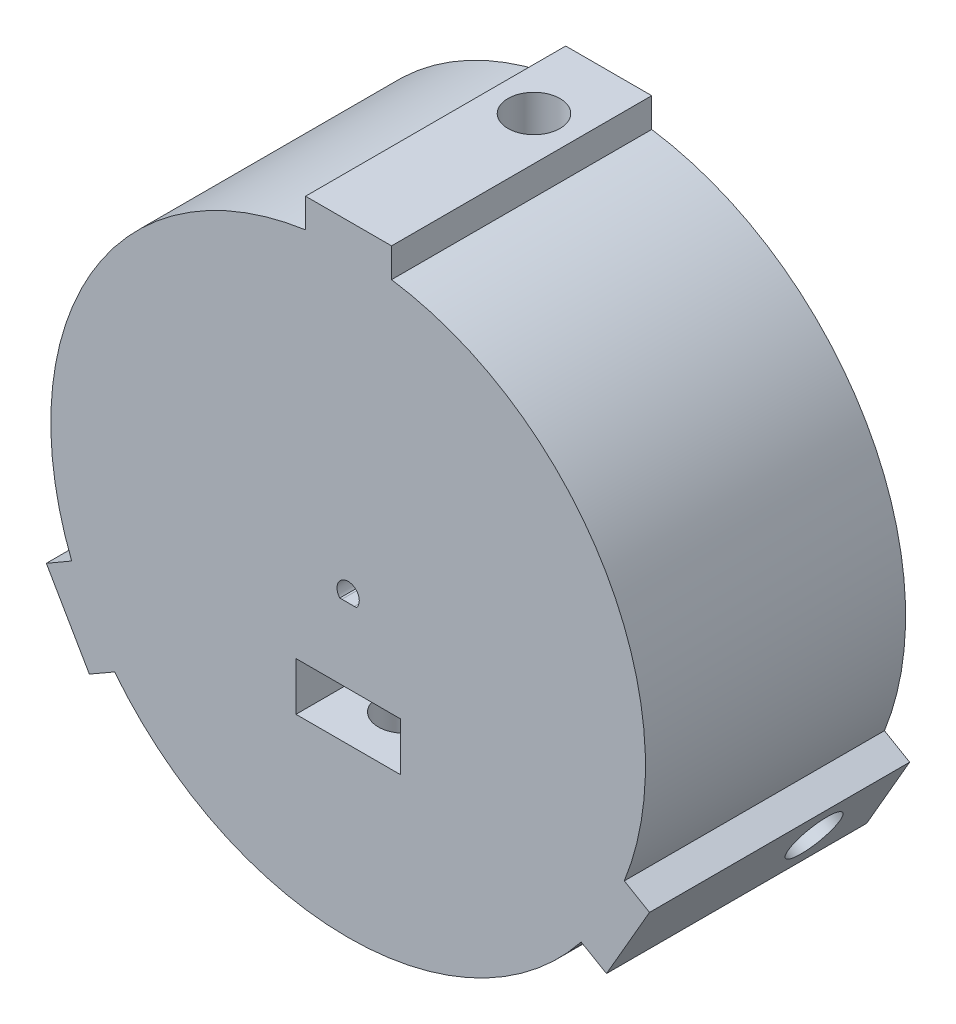
from build123d import *

# Parameters (mm, degrees)
SKETCH2_R                = 40
BOSS_EXTRUDE1_DEPTH      = 35
SKETCH3_W                = 8
SKETCH3_H                = 35
CUT_EXTRUDE1_DEPTH       = 20
SKETCH4_R                = 3.5
CUT_EXTRUDE2_DEPTH       = 80
SKETCH5_R                = 3.5
CUT_EXTRUDE3_DEPTH       = 50
SKETCH6_R                = 3.5
CUT_EXTRUDE4_DEPTH       = 50
SKETCH8_W                = 14.038446545
SKETCH8_H                = 6.5
CUT_EXTRUDE5_DEPTH       = 15.5
SKETCH11_W               = 8
SKETCH11_H               = 6.5
BOSS_EXTRUDE2_DEPTH      = 4.5
BOSS_EXTRUDE3_DEPTH      = 15.5
BOSS_EXTRUDE4_DEPTH      = 35
SKETCH18_R               = 3.5
CUT_EXTRUDE9_DEPTH       = 25
SKETCH19_R               = 3.5
CUT_EXTRUDE10_DEPTH      = 25
SKETCH20_R               = 3.5
CUT_EXTRUDE11_DEPTH      = 25
SKETCH21_W               = 5.1
SKETCH21_H               = 18.4
CUT_EXTRUDE12_DEPTH      = 13
SKETCH23_W               = 5.1
SKETCH23_H               = 18.4
CUT_EXTRUDE13_DEPTH      = 13
SKETCH22_W               = 5.1
SKETCH22_H               = 13.3
BOSS_EXTRUDE5_DEPTH      = 7.9
CUT_EXTRUDE14_DEPTH      = 8.5
SKETCH25_R               = 9
CUT_EXTRUDE15_DEPTH      = 20
SKETCH27_W               = 14.038446545
SKETCH27_H               = 6.5
CUT_EXTRUDE16_DEPTH      = 13
SKETCH28_R               = 3.5
CUT_EXTRUDE18_DEPTH      = 18
CUT_EXTRUDE18_DEPTH_BACK = 50


with BuildPart() as part:
    # Sketch2 → Boss-Extrude1 (new body)
    with BuildSketch(Plane.XY):
        Circle(SKETCH2_R)
    extrude(amount=BOSS_EXTRUDE1_DEPTH)

    # Sketch3 → Cut-Extrude1 (cut)
    with BuildSketch(Plane(origin=(0, 0, 0), x_dir=(-1, 0, 0), z_dir=(0, 0, -1))):
        with Locations((0, 21.5)):
            Rectangle(SKETCH3_W, SKETCH3_H)
        Polygon((31.774990748, -22.964101615), (35.774990748, -16.035898385), (5.464101615, 1.464101615), (1.464101615, -5.464101615), align=None)
        Polygon((-35.774990748, -16.035898385), (-31.774990748, -22.964101615), (-1.464101615, -5.464101615), (-5.464101615, 1.464101615), align=None)
    extrude(amount=-CUT_EXTRUDE1_DEPTH, mode=Mode.SUBTRACT)

    # Sketch4 → Cut-Extrude2 (cut)
    with BuildSketch(Plane(origin=(-3.464101615, -2, 0), x_dir=(0, 0, 1), z_dir=(-0.866025404, -0.5, 0))):
        with Locations((10, 0)):
            Circle(SKETCH4_R)
    extrude(amount=CUT_EXTRUDE2_DEPTH, mode=Mode.SUBTRACT)

    # Sketch5 → Cut-Extrude3 (cut)
    with BuildSketch(Plane(origin=(0, 4, 0), x_dir=(1, 0, 0), z_dir=(0, 1, 0))):
        with Locations((0, -10)):
            Circle(SKETCH5_R)
    extrude(amount=CUT_EXTRUDE3_DEPTH, mode=Mode.SUBTRACT)

    # Sketch6 → Cut-Extrude4 (cut)
    with BuildSketch(Plane(origin=(3.464101615, -2, 0), x_dir=(0, 0, -1), z_dir=(0.866025404, -0.5, 0))):
        with Locations((-10, 0)):
            Circle(SKETCH6_R)
    extrude(amount=CUT_EXTRUDE4_DEPTH, mode=Mode.SUBTRACT)

    # Sketch8 → Cut-Extrude5 (cut)
    with BuildSketch(Plane(origin=(0, 0, 0), x_dir=(-1, 0, 0), z_dir=(0, 0, -1))):
        Polygon((-32.971083956, -10.892407408), (-25.951860683, -23.050058746), (-20.322695558, -19.800058746), (-27.341918831, -7.642407408), align=None)
        with Locations((0.033217181, 30.75)):
            Rectangle(SKETCH8_W, SKETCH8_H)
        Polygon((27.30870165, -7.699941254), (32.937866774, -10.949941254), (25.918643502, -23.107592592), (20.289478377, -19.857592592), align=None)
    extrude(amount=-CUT_EXTRUDE5_DEPTH, mode=Mode.SUBTRACT)

    # Sketch11 → Boss-Extrude2 (add)
    with BuildSketch(Plane(origin=(0, 0, 20), x_dir=(-1, 0, 0), z_dir=(0, 0, -1))):
        with Locations((0, 30.75)):
            Rectangle(SKETCH11_W, SKETCH11_H)
        Polygon((25.815698604, -10.285898385), (31.444863729, -13.535898385), (27.444863729, -20.464101615), (21.815698604, -17.214101615), align=None)
        Polygon((-21.815698604, -17.214101615), (-27.444863729, -20.464101615), (-31.444863729, -13.535898385), (-25.815698604, -10.285898385), align=None)
    extrude(amount=BOSS_EXTRUDE2_DEPTH)

    # Sketch12 → Boss-Extrude3 (add)
    with BuildSketch(Plane(origin=(0, 0, 15.5), x_dir=(-1, 0, 0), z_dir=(0, 0, -1))):
        Polygon((-6.986006091, 32.1), (7.052440454, 32.1), (7.052440454, 34), (4, 34), (4, 39), (-4, 39), (-4, 34), (-6.986006091, 34), align=None)
        Polygon((25.918643502, -23.107592592), (27.444863729, -20.464101615), (31.774990748, -22.964101615), (35.774990748, -16.035898385), (31.444863729, -13.535898385), (32.937866774, -10.949941254), (31.292418507, -9.999941254), (24.273195235, -22.157592592), align=None)
        Polygon((-32.971083956, -10.892407408), (-31.444863729, -13.535898385), (-35.774990748, -16.035898385), (-31.774990748, -22.964101615), (-27.444863729, -20.464101615), (-25.951860683, -23.050058746), (-24.306412416, -22.100058746), (-31.325635688, -9.942407408), align=None)
    extrude(amount=BOSS_EXTRUDE3_DEPTH)

    # Sketch17 → Boss-Extrude4 (add)
    with BuildSketch(Plane(origin=(0, 0, 0), x_dir=(-1, 0, 0), z_dir=(0, 0, -1))):
        Polygon((-5.842787082, 32.897450406), (-5.842787082, 43.509531182), (5.727819383, 43.509531182), (5.754751517, 32.897450406), align=None)
        Polygon((31.411421312, -11.388723161), (25.612652013, -21.432486209), (34.816449619, -26.715202685), (40.601752851, -16.69476355), align=None)
        Polygon((-25.568634231, -21.508727245), (-31.36740353, -11.464964197), (-40.544269002, -16.794328497), (-34.75896577, -26.814767633), align=None)
    extrude(amount=-BOSS_EXTRUDE4_DEPTH)

    # Sketch18 → Cut-Extrude9 (cut, symmetric)
    with BuildSketch(Plane(origin=(-37.680359311, -21.754765591, 0), x_dir=(0, 0, 1), z_dir=(-0.866025404, -0.5, 0))):
        with Locations((10, 0)):
            Circle(SKETCH18_R)
    extrude(amount=CUT_EXTRUDE9_DEPTH, both=True, mode=Mode.SUBTRACT)

    # Sketch19 → Cut-Extrude10 (cut, symmetric)
    with BuildSketch(Plane(origin=(37.680359311, -21.754765591, 0), x_dir=(0, 0, -1), z_dir=(0.866025404, -0.5, 0))):
        with Locations((-10, 0)):
            Circle(SKETCH19_R)
    extrude(amount=CUT_EXTRUDE10_DEPTH, both=True, mode=Mode.SUBTRACT)

    # Sketch20 → Cut-Extrude11 (cut, symmetric)
    with BuildSketch(Plane(origin=(0, 43.509531182, 0), x_dir=(1, 0, 0), z_dir=(0, 1, 0))):
        with Locations((0, -10)):
            Circle(SKETCH20_R)
    extrude(amount=CUT_EXTRUDE11_DEPTH, both=True, mode=Mode.SUBTRACT)

    # Sketch21 → Cut-Extrude12 (cut)
    with BuildSketch(Plane(origin=(0, 0, 0), x_dir=(-1, 0, 0), z_dir=(0, 0, -1))):
        with Locations((6.55, 13.2)):
            Rectangle(SKETCH21_W, SKETCH21_H)
    extrude(amount=-CUT_EXTRUDE12_DEPTH, mode=Mode.SUBTRACT)

    # Sketch23 → Cut-Extrude13 (cut)
    with BuildSketch(Plane(origin=(0, 0, 0), x_dir=(-1, 0, 0), z_dir=(0, 0, -1))):
        with Locations((6.55, 13.2)):
            Rectangle(SKETCH23_W, SKETCH23_H)
        Polygon((-1.085898385, -9.880831174), (1.464101615, -5.464101615), (17.398969045, -14.664101615), (14.848969045, -19.080831174), align=None)
        Polygon((-8.014101615, 5.880831174), (-5.464101615, 1.464101615), (-21.398969045, -7.735898385), (-23.948969045, -3.319168826), align=None)
    extrude(amount=-CUT_EXTRUDE13_DEPTH, mode=Mode.SUBTRACT)

    # Sketch22 → Boss-Extrude5 (add)
    with BuildSketch(Plane(origin=(0, 0, 0), x_dir=(-1, 0, 0), z_dir=(0, 0, -1))):
        with Locations((6.55, 10.65)):
            Rectangle(SKETCH22_W, SKETCH22_H)
        Polygon((-1.085898385, -9.880831174), (1.464101615, -5.464101615), (12.982239485, -12.114101615), (10.432239485, -16.530831174), align=None)
        Polygon((-8.014101615, 5.880831174), (-5.464101615, 1.464101615), (-16.982239485, -5.185898385), (-19.532239485, -0.769168826), align=None)
    extrude(amount=-BOSS_EXTRUDE5_DEPTH)

    # Sketch24 → Cut-Extrude14 (cut)
    with BuildSketch(Plane.XY.offset(35)):
        with BuildLine():
            Line((0.831568399, -1), (1.11810064, -0.999925477))
            ThreePointArc((1.11810064, -0.999925477), (0.535186435, 1.401276375), (-1.5, 0))
            ThreePointArc((-1.5, 0), (-1.401274891, -0.535190321), (-1.118095094, -0.999931678))
            Line((-1.118095094, -0.999931678), (-0.831313787, -1))
            Line((-0.831313787, -1), (0.831568399, -1))
        make_face()
    extrude(amount=-CUT_EXTRUDE14_DEPTH, mode=Mode.SUBTRACT)

    # Sketch25 → Cut-Extrude15 (cut)
    with BuildSketch(Plane(origin=(0, 0, 0), x_dir=(-1, 0, 0), z_dir=(0, 0, -1))):
        Circle(SKETCH25_R)
    extrude(amount=-CUT_EXTRUDE15_DEPTH, mode=Mode.SUBTRACT)

    # Sketch27 → Cut-Extrude16 (cut)
    with BuildSketch(Plane.XY.offset(35)):
        with Locations((0.000904033, -14.25)):
            Rectangle(SKETCH27_W, SKETCH27_H)
    extrude(amount=-CUT_EXTRUDE16_DEPTH, mode=Mode.SUBTRACT)

    # Sketch28 → Cut-Extrude18 (cut, two sides)
    with BuildSketch(Plane(origin=(0, -17.5, 0), x_dir=(1, 0, 0), z_dir=(0, 1, 0))) as cut_extrude18_sk:
        with Locations((0, -27.44)):
            Circle(SKETCH28_R)
    extrude(amount=CUT_EXTRUDE18_DEPTH, mode=Mode.SUBTRACT)
    extrude(cut_extrude18_sk.sketch, amount=-CUT_EXTRUDE18_DEPTH_BACK, mode=Mode.SUBTRACT)


solid = part.part
